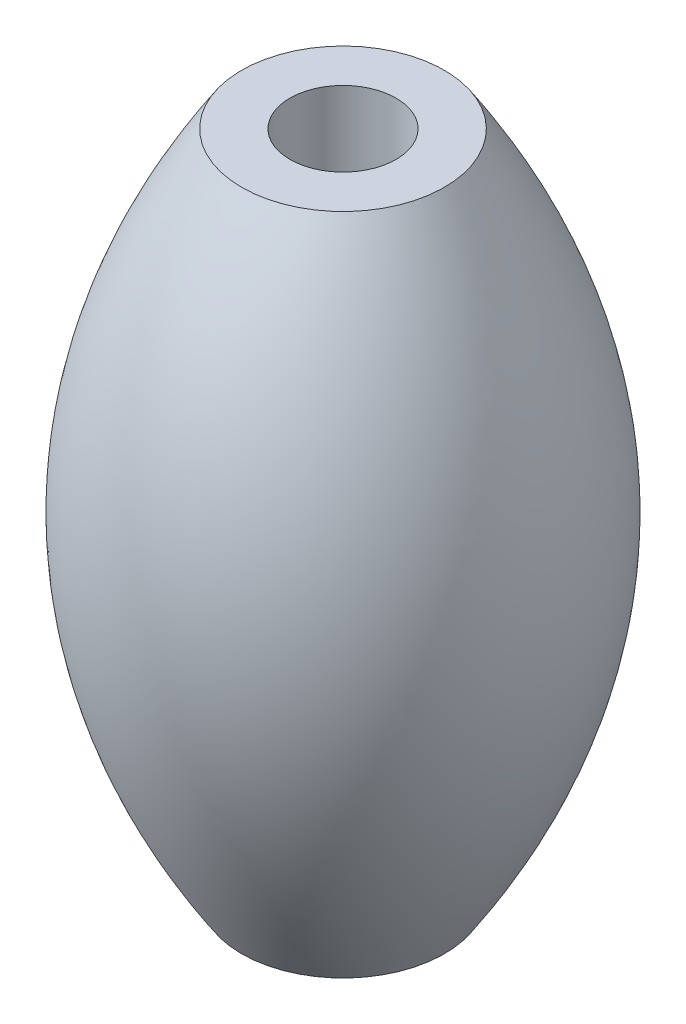
from build123d import *


with BuildPart() as part:
    # Sketch1 → Revolve1 (revolve)
    with BuildSketch(Plane.XY):
        with BuildLine():
            Line((2.2, 0), (2.2, 13.75))
            Line((2.2, 13.75), (4.2, 13.75))
            add(Edge.make_bspline(
                [(4.2, 13.75), (13.2, 0), (4.2, -13.75)],
                knots=[0, 0, 0, 1, 1, 1], degree=2))
            Line((4.2, -13.75), (2.2, -13.75))
            Line((2.2, -13.75), (2.2, 0))
        make_face()
    revolve(axis=Axis((0, 36.000042735, 0), (0, -1, 0)))


solid = part.part
